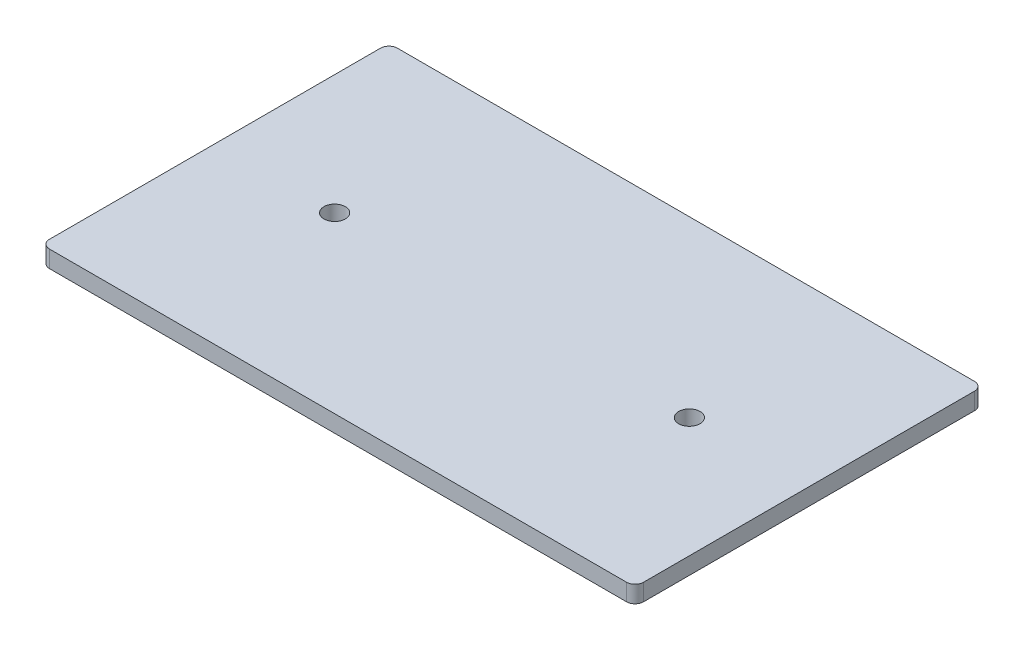
from build123d import *

# Parameters (mm, degrees)
SKETCH1_W           = 88.9
SKETCH1_H           = 52.07
BOSS_EXTRUDE1_DEPTH = 2.54
FILLET1_R           = 1.27
SKETCH2_R           = 1.6
CUT_EXTRUDE1_DEPTH  = 7.62


with BuildPart() as part:
    # Sketch1 → Boss-Extrude1 (new body)
    with BuildSketch(Plane(origin=(0, 0, 0), x_dir=(1, 0, 0), z_dir=(0, 1, 0))):
        Rectangle(SKETCH1_W, SKETCH1_H)
    extrude(amount=BOSS_EXTRUDE1_DEPTH)

    # Fillet1
    fillet1_edges = [part.edges().sort_by_distance(p)[0] for p in [
        (-44.45, 1.27, -26.035),
        (44.45, 1.27, -26.035),
        (44.45, 1.27, 26.035),
        (-44.45, 1.27, 26.035),
    ]]
    fillet(fillet1_edges, radius=FILLET1_R)

    # Sketch2 → Cut-Extrude1 (cut)
    with BuildSketch(Plane(origin=(0, 2.54, 0), x_dir=(1, 0, 0), z_dir=(0, 1, 0))):
        with Locations((-26.543, 0)):
            Circle(SKETCH2_R)
        with Locations((26.543, 0)):
            Circle(SKETCH2_R)
    extrude(amount=-CUT_EXTRUDE1_DEPTH, mode=Mode.SUBTRACT)


solid = part.part
